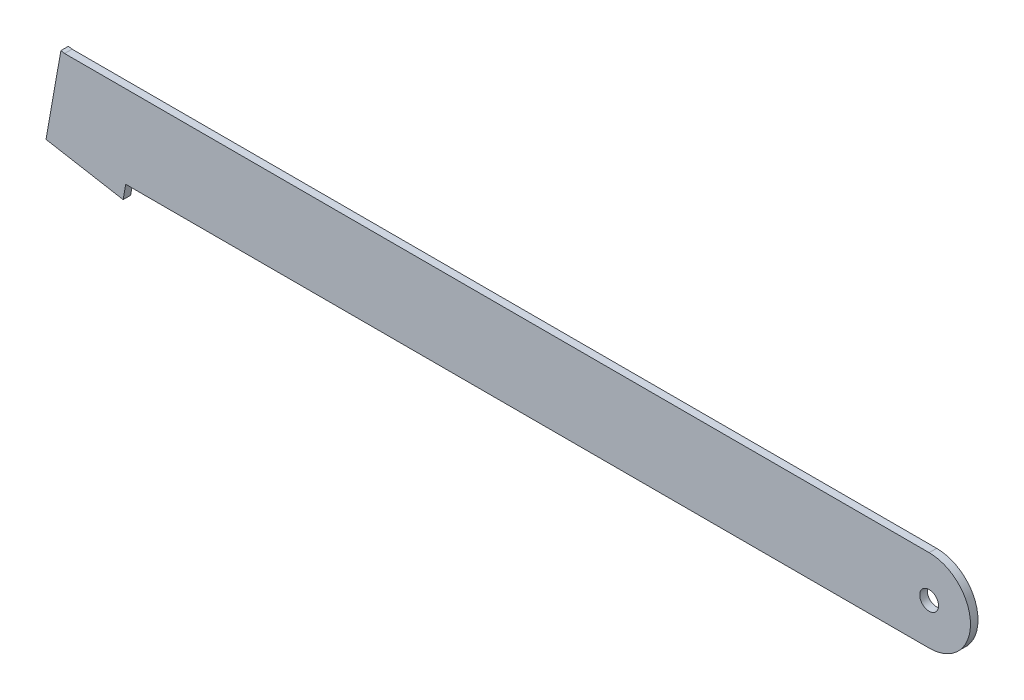
from build123d import *

# Parameters (mm, degrees)
SKETCH1_R           = 25
BOSS_EXTRUDE1_DEPTH = 10


with BuildPart() as part:
    # Sketch1 → Boss-Extrude1 (new body, symmetric)
    with BuildSketch(Plane.XY):
        with BuildLine():
            Line((-2300, 110.00001646), (-2309.84807753, 111.736498237))
            Line((-2309.84807753, 111.736498237), (-2344.209578927, -83.137259929))
            Line((-2344.209578927, -83.137259929), (-2349.419024257, -112.681492519))
            Line((-2349.419024257, -112.681492519), (-2144.255152103, -148.857418644))
            Line((-2144.255152103, -148.857418644), (-2137.403540795, -110))
            Line((-2137.403540795, -110), (0, -110))
            ThreePointArc((0, -110), (110.00000823, 8.23e-06), (0, 110.00001646))
            Line((0, 110.00001646), (-2300, 110.00001646))
        make_face()
        with Locations((0, 8.23e-06)):
            Circle(SKETCH1_R, mode=Mode.SUBTRACT)
    extrude(amount=BOSS_EXTRUDE1_DEPTH, both=True)


solid = part.part
